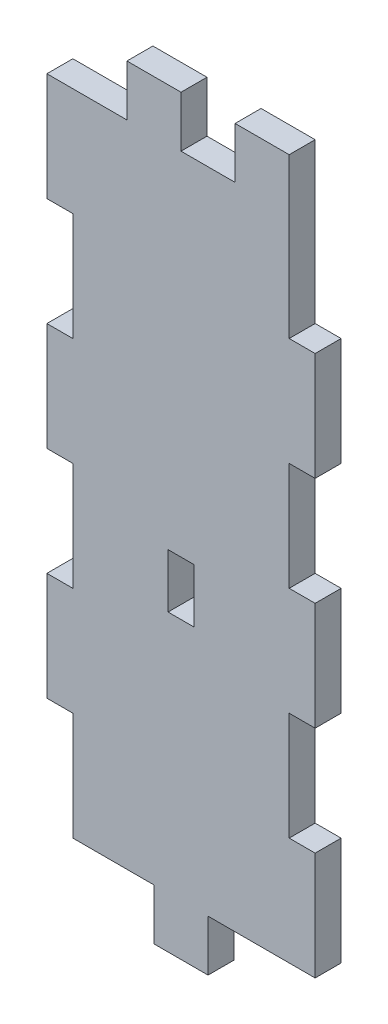
from build123d import *

# Parameters (mm, degrees)
SKETCH1_W           = 3.048
SKETCH1_H           = 6.35
BOSS_EXTRUDE1_DEPTH = 3.048


with BuildPart() as part:
    # Sketch1 → Boss-Extrude1 (new body)
    with BuildSketch(Plane.XY):
        Polygon((0, 0), (0, 12.7), (-3.048, 12.7), (-3.048, 25.4), (0, 25.4), (0, 38.1), (-3.048, 38.1), (-3.048, 50.8), (0, 50.8), (0, 63.5), (-3.048, 63.5), (-3.048, 76.2), (6.35, 76.2), (6.35, 82.1944), (12.7, 82.1944), (12.7, 76.2), (19.05, 76.2), (19.05, 82.1944), (25.4, 82.1944), (25.4, 63.5), (28.448, 63.5), (28.448, 50.8), (25.4, 50.8), (25.4, 38.1), (28.448, 38.1), (28.448, 25.4), (25.4, 25.4), (25.4, 12.7), (28.448, 12.7), (28.448, 0), (15.875, 0), (15.875, -5.9944), (9.525, -5.9944), (9.525, 0), align=None)
        with Locations((12.7, 31.75)):
            Rectangle(SKETCH1_W, SKETCH1_H, mode=Mode.SUBTRACT)
    extrude(amount=BOSS_EXTRUDE1_DEPTH)


solid = part.part
